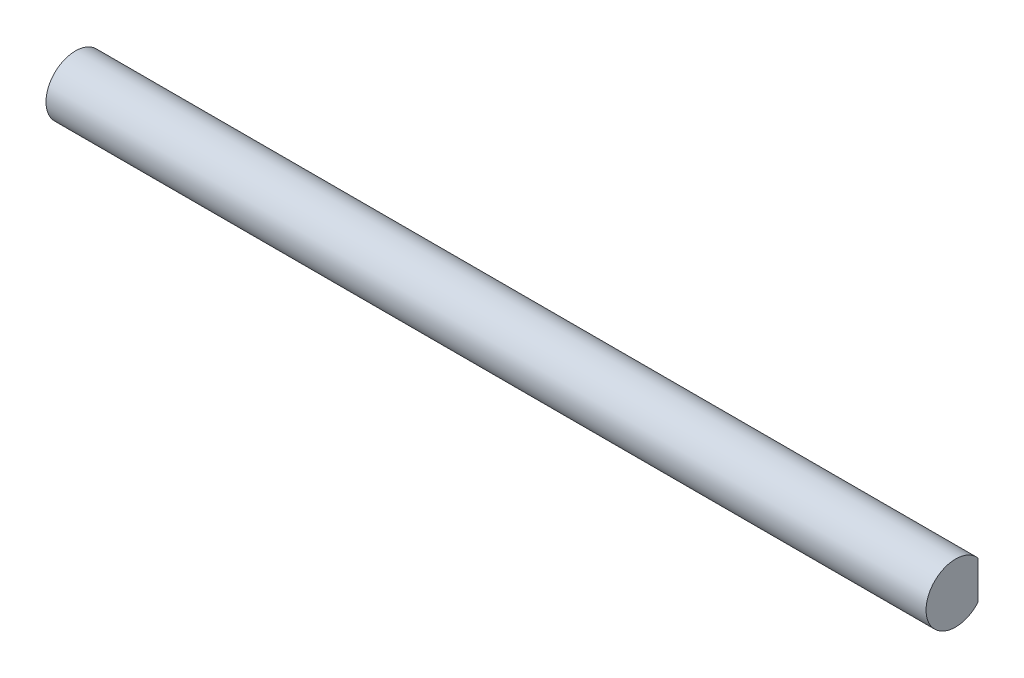
from build123d import *

# Parameters (mm, degrees)
BOSS_EXTRUDE1_DEPTH = 85


with BuildPart() as part:
    # Sketch1 → Boss-Extrude1 (new body)
    with BuildSketch(Plane(origin=(0, 0, 0), x_dir=(0, 0, -1), z_dir=(1, 0, 0))):
        with BuildLine():
            Line((2.167948339, 1.85), (2.167948339, -1.85))
            ThreePointArc((2.167948339, -1.85), (-2.85, 0), (2.167948339, 1.85))
        make_face()
    extrude(amount=BOSS_EXTRUDE1_DEPTH)


solid = part.part
